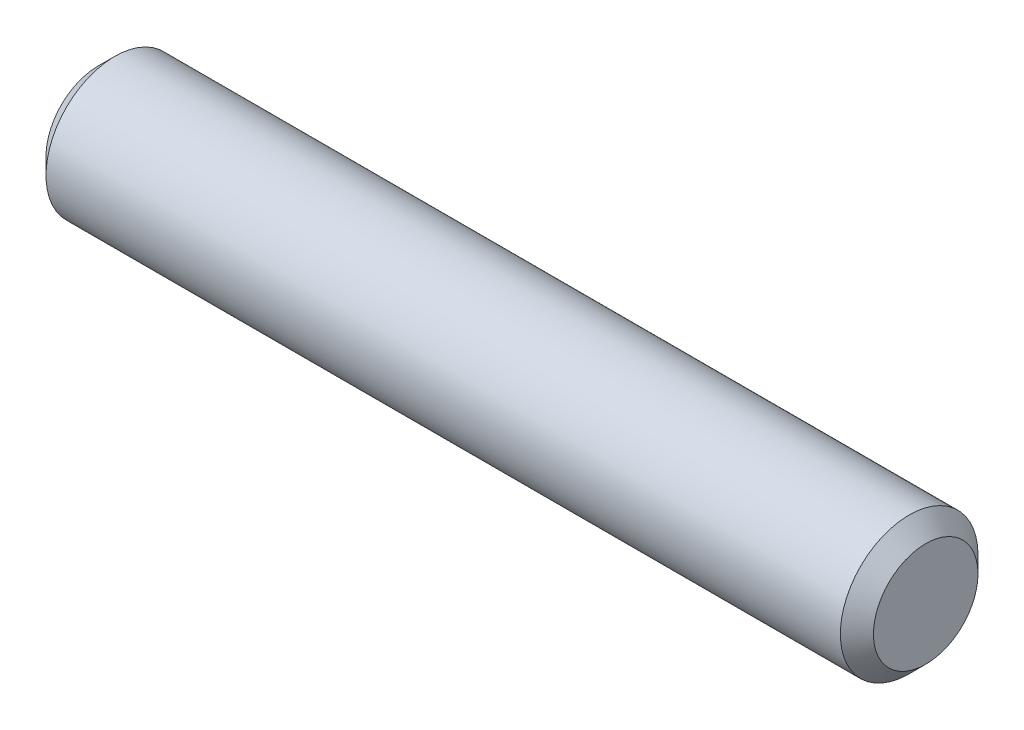
from build123d import *

# Parameters (mm, degrees)
SKETCH1_R           = 6.3373
BOSS_EXTRUDE1_DEPTH = 38.1
CHAMFER1_SIZE       = 1.524
CHAMFER2_SIZE       = 1.524


with BuildPart() as part:
    # Sketch1 → Boss-Extrude1 (new body, symmetric)
    with BuildSketch(Plane(origin=(0, 0, 0), x_dir=(0, 0, -1), z_dir=(1, 0, 0))):
        Circle(SKETCH1_R)
    extrude(amount=BOSS_EXTRUDE1_DEPTH, both=True)

    # Chamfer1
    chamfer1_edges = [part.edges().sort_by_distance(p)[0] for p in [
        (38.1, 0, 6.3373),
    ]]
    chamfer(chamfer1_edges, length=CHAMFER1_SIZE)

    # Chamfer2
    chamfer2_edges = [part.edges().sort_by_distance(p)[0] for p in [
        (-38.1, 0, 6.3373),
    ]]
    chamfer(chamfer2_edges, length=CHAMFER2_SIZE)


solid = part.part
